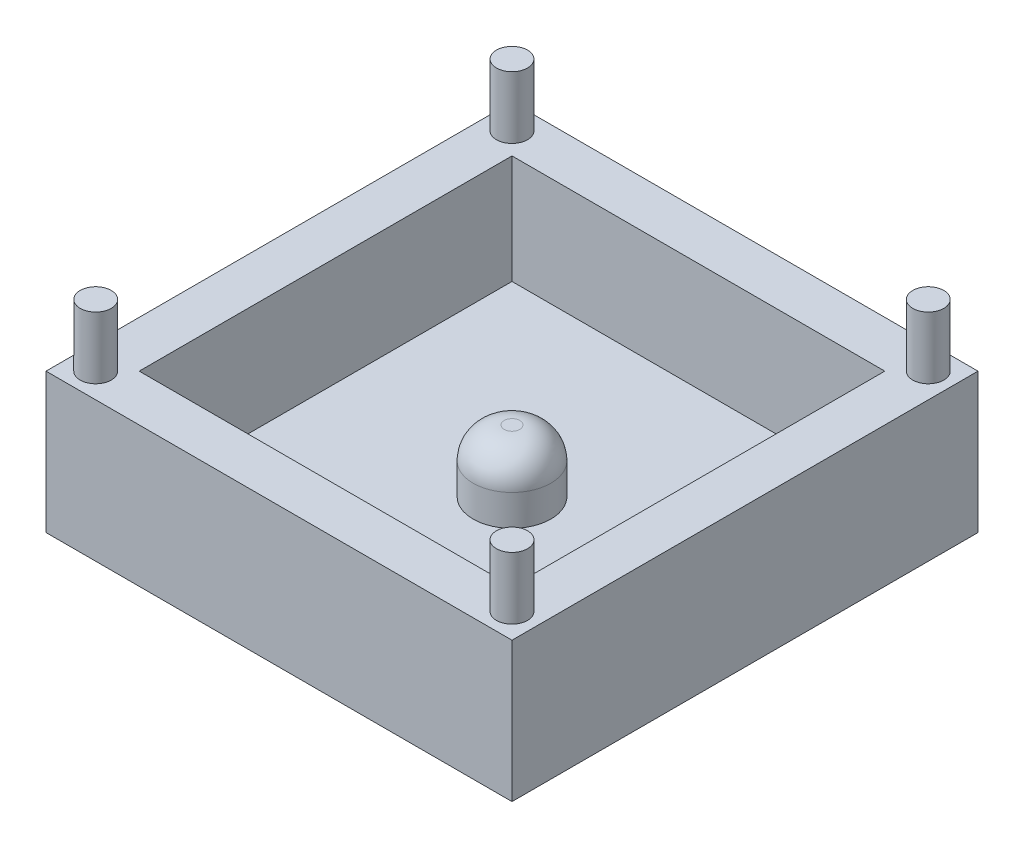
from build123d import *

# Parameters (mm, degrees)
SKETCH1_W           = 15
SKETCH1_H           = 15
BOSS_EXTRUDE1_DEPTH = 4.5
SKETCH2_W           = 12
SKETCH2_H           = 12
CUT_EXTRUDE1_DEPTH  = 3.5
SKETCH3_R           = 1.25
BOSS_EXTRUDE2_DEPTH = 2
FILLET1_R           = 1
SKETCH4_R           = 0.5
BOSS_EXTRUDE3_DEPTH = 2


with BuildPart() as part:
    # Sketch1 → Boss-Extrude1 (new body)
    with BuildSketch(Plane(origin=(0, 0, 0), x_dir=(1, 0, 0), z_dir=(0, 1, 0))):
        Rectangle(SKETCH1_W, SKETCH1_H)
    extrude(amount=BOSS_EXTRUDE1_DEPTH)

    # Sketch2 → Cut-Extrude1 (cut)
    with BuildSketch(Plane(origin=(0, 4.5, 0), x_dir=(1, 0, 0), z_dir=(0, 1, 0))):
        Rectangle(SKETCH2_W, SKETCH2_H)
    extrude(amount=-CUT_EXTRUDE1_DEPTH, mode=Mode.SUBTRACT)

    # Sketch3 → Boss-Extrude2 (add)
    with BuildSketch(Plane(origin=(0, 1, 0), x_dir=(1, 0, 0), z_dir=(0, 1, 0))):
        Circle(SKETCH3_R)
    extrude(amount=BOSS_EXTRUDE2_DEPTH)

    # Fillet1
    fillet1_edges = [part.edges().sort_by_distance(p)[0] for p in [
        (-1.25, 3, 0),
    ]]
    fillet(fillet1_edges, radius=FILLET1_R)

    # Sketch4 → Boss-Extrude3 (add)
    with BuildSketch(Plane(origin=(0, 4.5, 0), x_dir=(1, 0, 0), z_dir=(0, 1, 0))):
        with Locations((-6.7, 6.7)):
            Circle(SKETCH4_R)
        with Locations((6.7, 6.7)):
            Circle(SKETCH4_R)
        with Locations((6.7, -6.7)):
            Circle(SKETCH4_R)
        with Locations((-6.7, -6.7)):
            Circle(SKETCH4_R)
    extrude(amount=BOSS_EXTRUDE3_DEPTH)


solid = part.part
